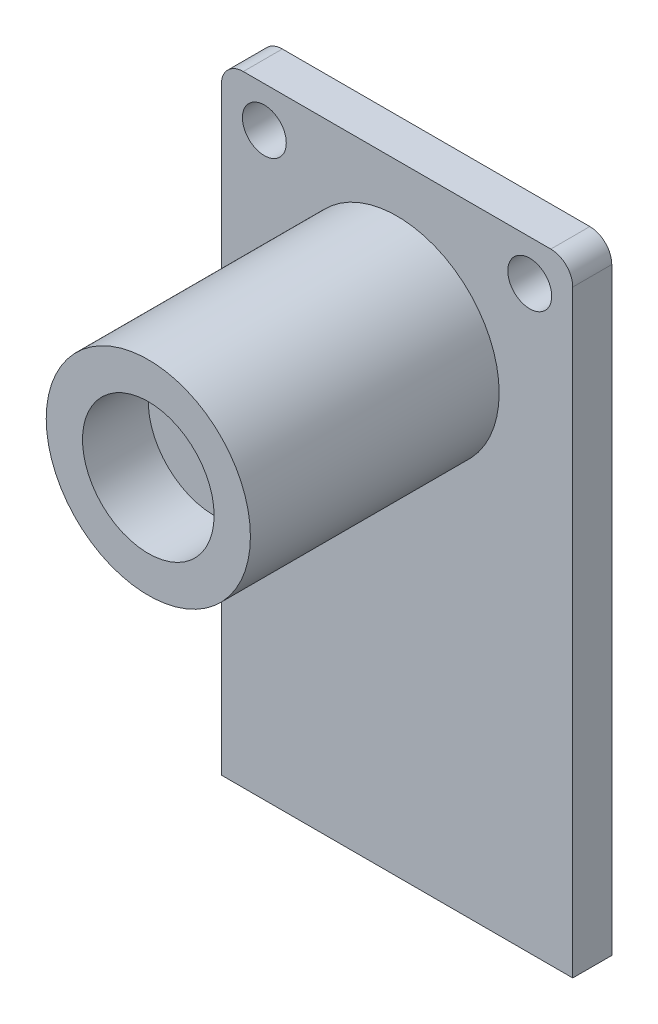
from build123d import *

# Parameters (mm, degrees)
BOSS_EXTRUDE1_DEPTH = 1.78
SKETCH2_R           = 4.655
BOSS_EXTRUDE2_DEPTH = 11.34
SKETCH3_R           = 3
CUT_EXTRUDE1_DEPTH  = 3
SKETCH4_R           = 1
CUT_EXTRUDE2_DEPTH  = 3


with BuildPart() as part:
    # Sketch1 → Boss-Extrude1 (new body)
    with BuildSketch(Plane.XY):
        with BuildLine():
            Line((8.01, -14.14), (-8.01, -14.14))
            Line((-8.01, -14.14), (-8.01, 13.14))
            ThreePointArc((-8.01, 13.14), (-7.717106781, 13.847106781), (-7.01, 14.14))
            Line((-7.01, 14.14), (7.01, 14.14))
            ThreePointArc((7.01, 14.14), (7.717106781, 13.847106781), (8.01, 13.14))
            Line((8.01, 13.14), (8.01, -14.14))
        make_face()
    extrude(amount=BOSS_EXTRUDE1_DEPTH)

    # Sketch2 → Boss-Extrude2 (add)
    with BuildSketch(Plane.XY.offset(1.78)):
        with Locations((0, 7.285)):
            Circle(SKETCH2_R)
    extrude(amount=BOSS_EXTRUDE2_DEPTH)

    # Sketch3 → Cut-Extrude1 (cut)
    with BuildSketch(Plane.XY.offset(13.12)):
        with Locations((0, 7.285)):
            Circle(SKETCH3_R)
    extrude(amount=-CUT_EXTRUDE1_DEPTH, mode=Mode.SUBTRACT)

    # Sketch4 → Cut-Extrude2 (cut)
    with BuildSketch(Plane.XY.offset(1.78)):
        with Locations((6.05, 12.299860012)):
            Circle(SKETCH4_R)
        with Locations((-6.05, 12.299860012)):
            Circle(SKETCH4_R)
    extrude(amount=-CUT_EXTRUDE2_DEPTH, mode=Mode.SUBTRACT)


solid = part.part
